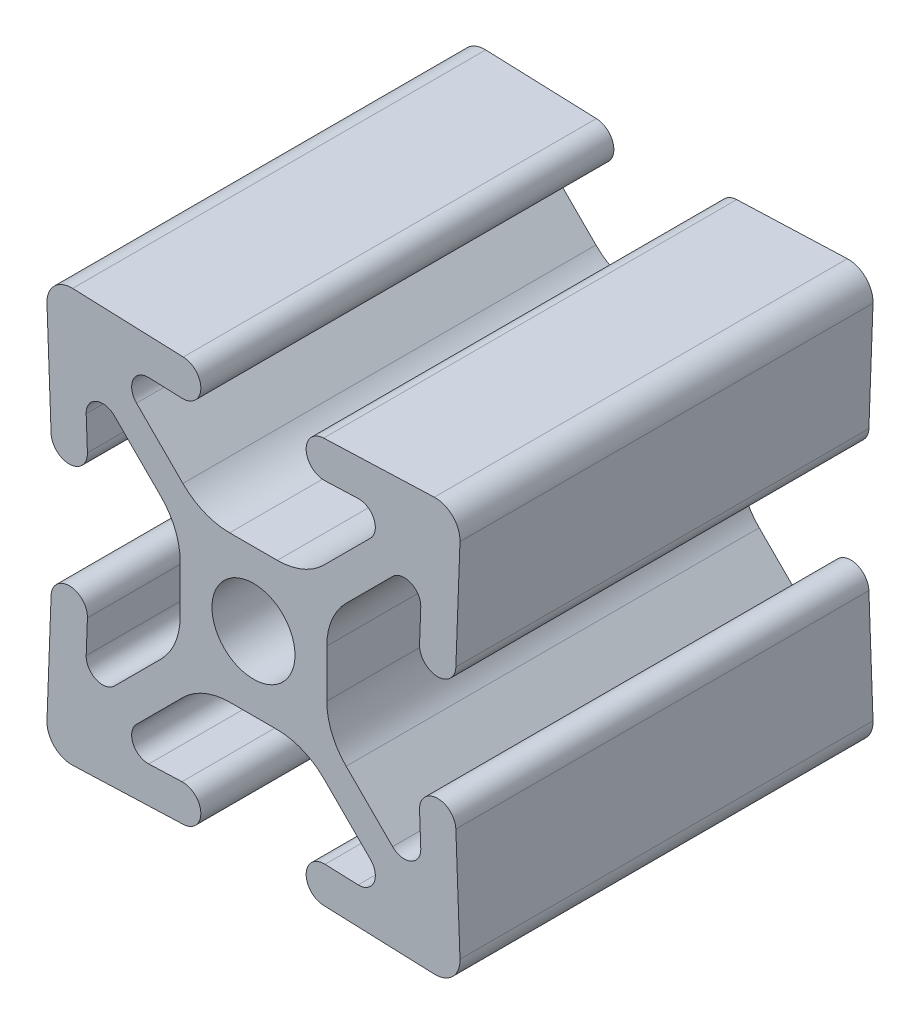
from build123d import *

# Parameters (mm, degrees)
EXTRUDE1_DEPTH = 25.4


with BuildPart() as part:
    # Sketch1 → Extrude1 (new body)
    with BuildSketch(Plane.XY):
        with BuildLine():
            Line((11.119216576, 12.698941773), (4.314458822, 12.445223967))
            ThreePointArc((4.314458822, 12.445223967), (3.239276033, 11.286758822), (4.397741178, 10.211576033))
            Line((4.397741178, 10.211576033), (6.439144384, 10.287690476))
            ThreePointArc((6.439144384, 10.287690476), (7.408254029, 9.678624879), (7.19542049, 8.553975471))
            Line((7.19542049, 8.553975471), (4.34026306, 5.698818041))
            ThreePointArc((4.34026306, 5.698818041), (3.02180657, 4.81785358), (1.466581101, 4.5085))
            Line((1.466581101, 4.5085), (0, 4.5085))
            Line((0, 4.5085), (-1.466581101, 4.5085))
            ThreePointArc((-1.466581101, 4.5085), (-3.02180657, 4.81785358), (-4.34026306, 5.698818041))
            Line((-4.34026306, 5.698818041), (-7.19542049, 8.553975471))
            ThreePointArc((-7.19542049, 8.553975471), (-7.408254029, 9.678624879), (-6.439144384, 10.287690476))
            Line((-6.439144384, 10.287690476), (-4.397741178, 10.211576033))
            ThreePointArc((-4.397741178, 10.211576033), (-3.239276033, 11.286758822), (-4.314458822, 12.445223967))
            Line((-4.314458822, 12.445223967), (-11.119216576, 12.698941773))
            ThreePointArc((-11.119216576, 12.698941773), (-11.732873224, 12.594614892), (-12.253630735, 12.253630735))
            ThreePointArc((-12.253630735, 12.253630735), (-12.594614892, 11.732873224), (-12.698941773, 11.119216576))
            Line((-12.698941773, 11.119216576), (-12.445223967, 4.314458822))
            ThreePointArc((-12.445223967, 4.314458822), (-11.286758822, 3.239276033), (-10.211576033, 4.397741178))
            Line((-10.211576033, 4.397741178), (-10.287690476, 6.439144384))
            ThreePointArc((-10.287690476, 6.439144384), (-9.678624879, 7.408254029), (-8.553975471, 7.19542049))
            Line((-8.553975471, 7.19542049), (-5.698818041, 4.34026306))
            ThreePointArc((-5.698818041, 4.34026306), (-4.81785358, 3.02180657), (-4.5085, 1.466581101))
            Line((-4.5085, 1.466581101), (-4.5085, 0))
            Line((-4.5085, 0), (-4.5085, -1.466581101))
            ThreePointArc((-4.5085, -1.466581101), (-4.81785358, -3.02180657), (-5.698818041, -4.34026306))
            Line((-5.698818041, -4.34026306), (-8.553975471, -7.19542049))
            ThreePointArc((-8.553975471, -7.19542049), (-9.678624879, -7.408254029), (-10.287690476, -6.439144384))
            Line((-10.287690476, -6.439144384), (-10.211576033, -4.397741178))
            ThreePointArc((-10.211576033, -4.397741178), (-11.286758822, -3.239276033), (-12.445223967, -4.314458822))
            Line((-12.445223967, -4.314458822), (-12.698941773, -11.119216576))
            ThreePointArc((-12.698941773, -11.119216576), (-12.594614892, -11.732873224), (-12.253630735, -12.253630735))
            ThreePointArc((-12.253630735, -12.253630735), (-11.732873224, -12.594614892), (-11.119216576, -12.698941773))
            Line((-11.119216576, -12.698941773), (-4.314458822, -12.445223967))
            ThreePointArc((-4.314458822, -12.445223967), (-3.239276033, -11.286758822), (-4.397741178, -10.211576033))
            Line((-4.397741178, -10.211576033), (-6.439144384, -10.287690476))
            ThreePointArc((-6.439144384, -10.287690476), (-7.408254029, -9.678624879), (-7.19542049, -8.553975471))
            Line((-7.19542049, -8.553975471), (-4.34026306, -5.698818041))
            ThreePointArc((-4.34026306, -5.698818041), (-3.02180657, -4.81785358), (-1.466581101, -4.5085))
            Line((-1.466581101, -4.5085), (0, -4.5085))
            Line((0, -4.5085), (1.466581101, -4.5085))
            ThreePointArc((1.466581101, -4.5085), (3.02180657, -4.81785358), (4.34026306, -5.698818041))
            Line((4.34026306, -5.698818041), (7.19542049, -8.553975471))
            ThreePointArc((7.19542049, -8.553975471), (7.408254029, -9.678624879), (6.439144384, -10.287690476))
            Line((6.439144384, -10.287690476), (4.397741178, -10.211576033))
            ThreePointArc((4.397741178, -10.211576033), (3.239276033, -11.286758822), (4.314458822, -12.445223967))
            Line((4.314458822, -12.445223967), (11.119216576, -12.698941773))
            ThreePointArc((11.119216576, -12.698941773), (11.732873224, -12.594614892), (12.253630735, -12.253630735))
            ThreePointArc((12.253630735, -12.253630735), (12.594614892, -11.732873224), (12.698941773, -11.119216576))
            Line((12.698941773, -11.119216576), (12.445223967, -4.314458822))
            ThreePointArc((12.445223967, -4.314458822), (11.286758822, -3.239276033), (10.211576033, -4.397741178))
            Line((10.211576033, -4.397741178), (10.287690476, -6.439144384))
            ThreePointArc((10.287690476, -6.439144384), (9.678624879, -7.408254029), (8.553975471, -7.19542049))
            Line((8.553975471, -7.19542049), (5.698818041, -4.34026306))
            ThreePointArc((5.698818041, -4.34026306), (4.81785358, -3.02180657), (4.5085, -1.466581101))
            Line((4.5085, -1.466581101), (4.5085, 0))
            Line((4.5085, 0), (4.5085, 1.466581101))
            ThreePointArc((4.5085, 1.466581101), (4.81785358, 3.02180657), (5.698818041, 4.34026306))
            Line((5.698818041, 4.34026306), (8.553975471, 7.19542049))
            ThreePointArc((8.553975471, 7.19542049), (9.678624879, 7.408254029), (10.287690476, 6.439144384))
            Line((10.287690476, 6.439144384), (10.211576033, 4.397741178))
            ThreePointArc((10.211576033, 4.397741178), (11.286758822, 3.239276033), (12.445223967, 4.314458822))
            Line((12.445223967, 4.314458822), (12.698941773, 11.119216576))
            ThreePointArc((12.698941773, 11.119216576), (12.594614892, 11.732873224), (12.253630735, 12.253630735))
            ThreePointArc((12.253630735, 12.253630735), (11.732873224, 12.594614892), (11.119216576, 12.698941773))
        make_face()
        with BuildLine():
            ThreePointArc((1.80503148, 1.80503148), (0.976875998, 2.358387283), (0, 2.5527))
            ThreePointArc((0, 2.5527), (-0.976875998, 2.358387283), (-1.80503148, 1.80503148))
            ThreePointArc((-1.80503148, 1.80503148), (-2.358387283, 0.976875998), (-2.5527, 0))
            ThreePointArc((-2.5527, 0), (-2.358387283, -0.976875998), (-1.80503148, -1.80503148))
            ThreePointArc((-1.80503148, -1.80503148), (-0.976875998, -2.358387283), (0, -2.5527))
            ThreePointArc((0, -2.5527), (0.976875998, -2.358387283), (1.80503148, -1.80503148))
            ThreePointArc((1.80503148, -1.80503148), (2.358387283, -0.976875998), (2.5527, 0))
            ThreePointArc((2.5527, 0), (2.358387283, 0.976875998), (1.80503148, 1.80503148))
        make_face(mode=Mode.SUBTRACT)
    extrude(amount=EXTRUDE1_DEPTH)


solid = part.part
